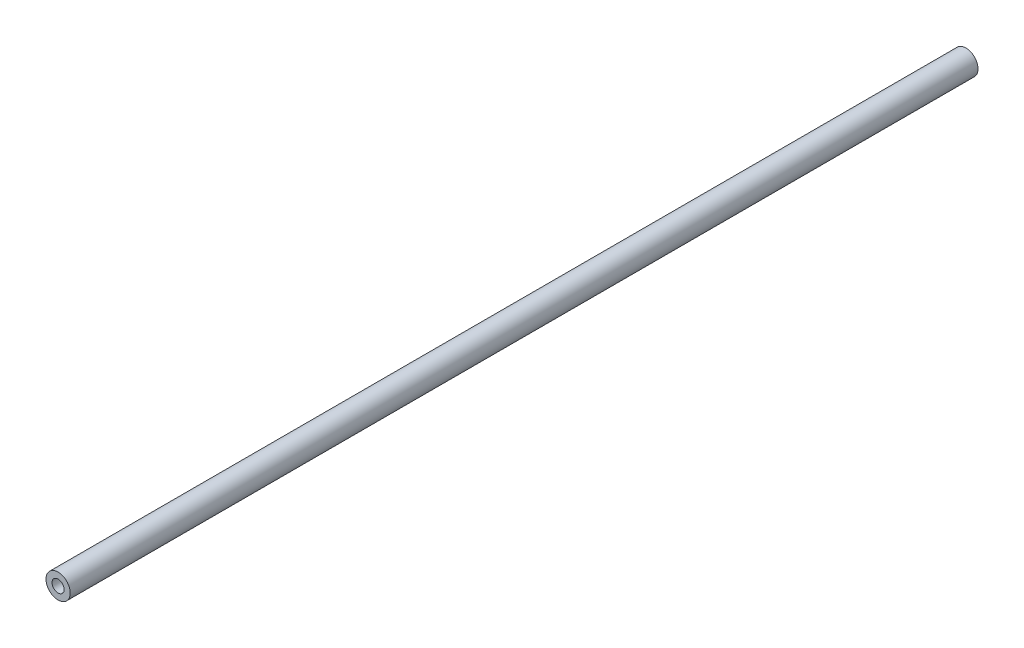
from build123d import *

# Parameters (mm, degrees)
ESBO_O1_W = 1
ESBO_O1_H = 150


with BuildPart() as part:
    # Esboço1 → Revolução1 (revolve)
    with BuildSketch(Plane(origin=(0, 0, 0), x_dir=(1, 0, 0), z_dir=(0, 1, 0))):
        with Locations((-1.5, 0)):
            Rectangle(ESBO_O1_W, ESBO_O1_H)
    revolve(axis=Axis((0, 0, 0), (0, 0, -1)))


solid = part.part
